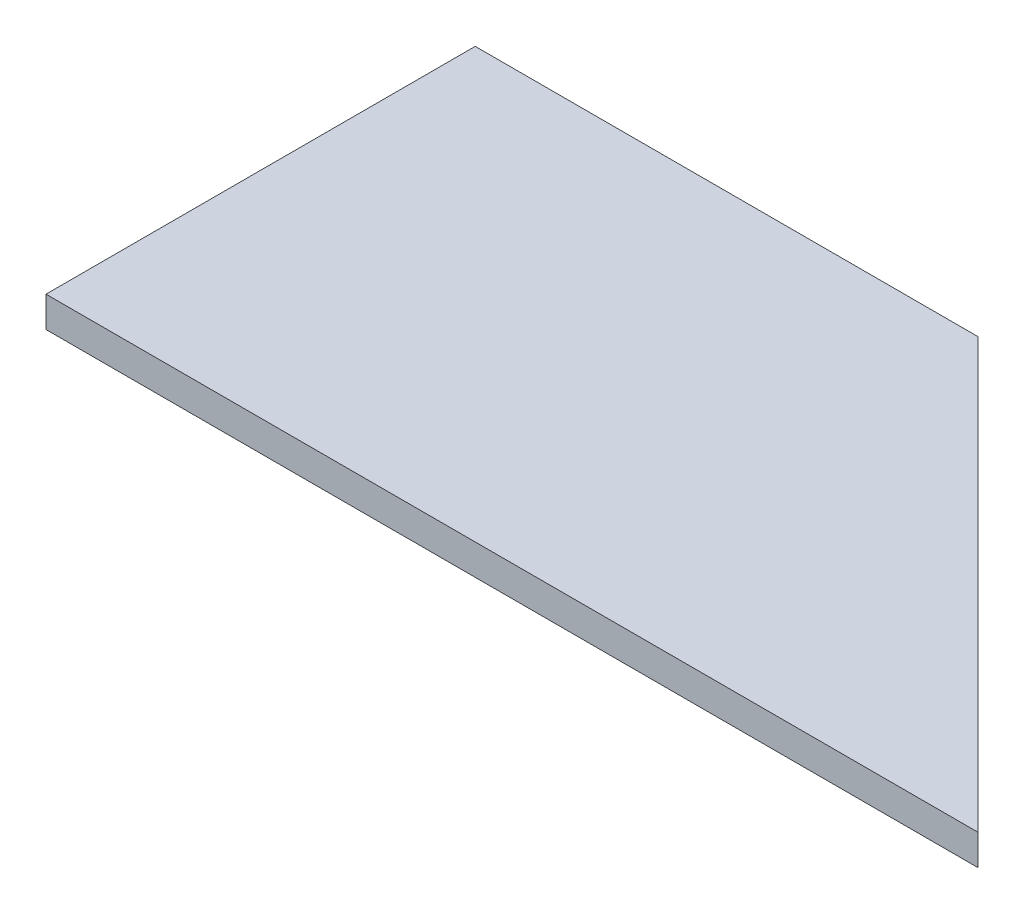
from build123d import *

# Parameters (mm, degrees)
BOSS_EXTRUDE1_DEPTH = 3


with BuildPart() as part:
    # Sketch1 → Boss-Extrude1 (new body)
    with BuildSketch(Plane(origin=(0, 0, 0), x_dir=(1, 0, 0), z_dir=(0, 1, 0))):
        Polygon((45.6, -21), (3.595714504, 21), (-45.6, 21), (-45.6, -21), align=None)
    extrude(amount=BOSS_EXTRUDE1_DEPTH)


solid = part.part
